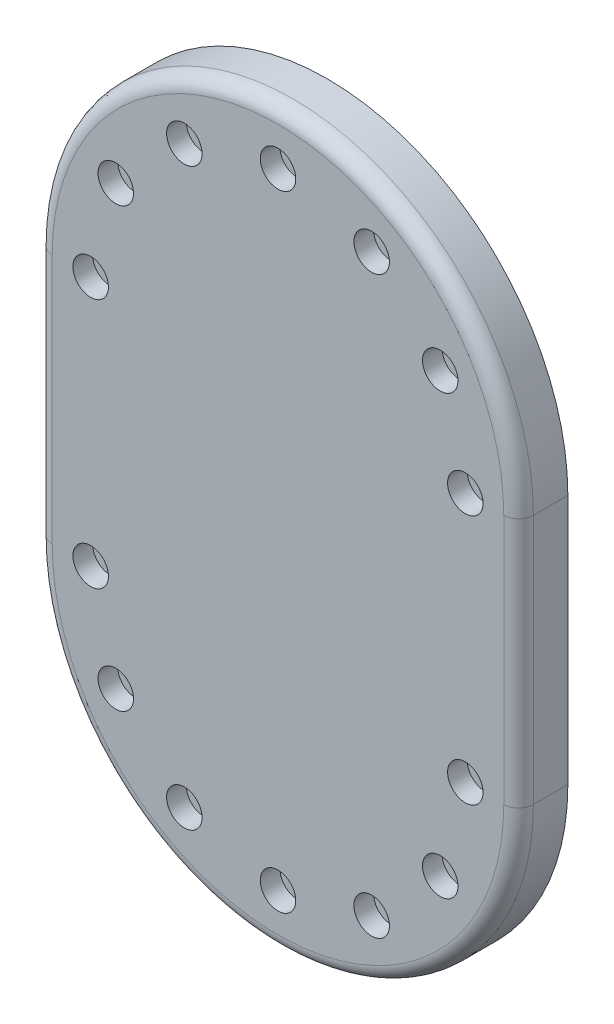
from build123d import *

# Parameters (mm, degrees)
BOSS_EXTRUDE1_DEPTH        = 12.5
CUT_EXTRUDE1_DEPTH         = 6.25
FILLET1_R                  = 1.75
FILLET2_R                  = 3.75
HOLE1_D                    = 5
HOLE1_DEPTH                = 30
HOLE1_CBORE_D              = 9
HOLE1_CBORE_DEPTH          = 5
CIRPATTERN1_COUNT          = 7
CIRPATTERN1_ANGLE          = 180
MIRROR1_COPY_1_D           = 5
MIRROR1_COPY_1_DEPTH       = 30
MIRROR1_COPY_1_CBORE_D     = 9
MIRROR1_COPY_1_CBORE_DEPTH = 5
MIRROR1_COPY_2_D           = 5
MIRROR1_COPY_2_DEPTH       = 30
MIRROR1_COPY_2_CBORE_D     = 9
MIRROR1_COPY_2_CBORE_DEPTH = 5
MIRROR1_COPY_3_D           = 5
MIRROR1_COPY_3_DEPTH       = 30
MIRROR1_COPY_3_CBORE_D     = 9
MIRROR1_COPY_3_CBORE_DEPTH = 5
MIRROR1_COPY_4_D           = 5
MIRROR1_COPY_4_DEPTH       = 30
MIRROR1_COPY_4_CBORE_D     = 9
MIRROR1_COPY_4_CBORE_DEPTH = 5
MIRROR1_COPY_5_D           = 5
MIRROR1_COPY_5_DEPTH       = 30
MIRROR1_COPY_5_CBORE_D     = 9
MIRROR1_COPY_5_CBORE_DEPTH = 5
MIRROR1_COPY_6_D           = 5
MIRROR1_COPY_6_DEPTH       = 30
MIRROR1_COPY_6_CBORE_D     = 9
MIRROR1_COPY_6_CBORE_DEPTH = 5


with BuildPart() as part:
    # Sketch1 → Boss-Extrude1 (new body)
    with BuildSketch(Plane.XY):
        with BuildLine():
            Line((61, 31.75), (61, -31.75))
            ThreePointArc((61, -31.75), (0, -92.75), (-61, -31.75))
            Line((-61, -31.75), (-61, 31.75))
            ThreePointArc((-61, 31.75), (0, 92.75), (61, 31.75))
        make_face()
    extrude(amount=BOSS_EXTRUDE1_DEPTH)

    # Sketch1_3 → Cut-Extrude1 (cut)
    with BuildSketch(Plane.XY):
        with BuildLine():
            Line((-11.5, 31.75), (-11.5, -31.75))
            ThreePointArc((-11.5, -31.75), (0, -43.25), (11.5, -31.75))
            Line((11.5, -31.75), (11.5, 31.75))
            ThreePointArc((11.5, 31.75), (0, 43.25), (-11.5, 31.75))
        make_face()
    extrude(amount=CUT_EXTRUDE1_DEPTH, mode=Mode.SUBTRACT)

    # Fillet1
    fillet1_edges = [part.edges().sort_by_distance(p)[0] for p in [
        (-11.5, 0, 0),
        (0, -43.25, 0),
        (0, 43.25, 0),
        (11.5, 0, 0),
    ]]
    fillet(fillet1_edges, radius=FILLET1_R)

    # Fillet2
    fillet2_edges = [part.edges().sort_by_distance(p)[0] for p in [
        (0, -92.75, 12.5),
        (61, 0, 12.5),
        (0, 92.75, 12.5),
        (-61, 0, 12.5),
    ]]
    fillet(fillet2_edges, radius=FILLET2_R)

    # Hole1
    with Locations(Plane.XY.offset(12.5)):
        with Locations((-47.5, 31.75)):
            hole1 = CounterBoreHole(HOLE1_D / 2, HOLE1_CBORE_D / 2, HOLE1_CBORE_DEPTH, depth=HOLE1_DEPTH)

    # CirPattern1: Hole1 ×7 about axis
    cirpattern1_axis = Axis((0, 31.75, 0), (0, 0, -1))
    for i in range(1, CIRPATTERN1_COUNT):
        add(hole1.rotate(cirpattern1_axis, i * CIRPATTERN1_ANGLE / (CIRPATTERN1_COUNT - 1)), mode=Mode.SUBTRACT)

    # Mirror1: Hole1 across plane
    add(hole1.mirror(Plane.ZX), mode=Mode.SUBTRACT)

    # Mirror1 copy 1
    with Locations(Plane(origin=(-15.875, -4.25369343, 12.5), x_dir=(0.866025404, 0.5, 0), z_dir=(0, 0, 1))):
        with Locations((-47.5, -31.75)):
            CounterBoreHole(MIRROR1_COPY_1_D / 2, MIRROR1_COPY_1_CBORE_D / 2, MIRROR1_COPY_1_CBORE_DEPTH, depth=MIRROR1_COPY_1_DEPTH)

    # Mirror1 copy 2
    with Locations(Plane(origin=(-27.49630657, -15.875, 12.5), x_dir=(0.5, 0.866025404, 0), z_dir=(0, 0, 1))):
        with Locations((-47.5, -31.75)):
            CounterBoreHole(MIRROR1_COPY_2_D / 2, MIRROR1_COPY_2_CBORE_D / 2, MIRROR1_COPY_2_CBORE_DEPTH, depth=MIRROR1_COPY_2_DEPTH)

    # Mirror1 copy 3
    with Locations(Plane(origin=(-31.75, -31.75, 12.5), x_dir=(0, 1, 0), z_dir=(0, 0, 1))):
        with Locations((-47.5, -31.75)):
            CounterBoreHole(MIRROR1_COPY_3_D / 2, MIRROR1_COPY_3_CBORE_D / 2, MIRROR1_COPY_3_CBORE_DEPTH, depth=MIRROR1_COPY_3_DEPTH)

    # Mirror1 copy 4
    with Locations(Plane(origin=(-27.49630657, -47.625, 12.5), x_dir=(-0.5, 0.866025404, 0), z_dir=(0, 0, 1))):
        with Locations((-47.5, -31.75)):
            CounterBoreHole(MIRROR1_COPY_4_D / 2, MIRROR1_COPY_4_CBORE_D / 2, MIRROR1_COPY_4_CBORE_DEPTH, depth=MIRROR1_COPY_4_DEPTH)

    # Mirror1 copy 5
    with Locations(Plane(origin=(-15.875, -59.24630657, 12.5), x_dir=(-0.866025404, 0.5, 0), z_dir=(0, 0, 1))):
        with Locations((-47.5, -31.75)):
            CounterBoreHole(MIRROR1_COPY_5_D / 2, MIRROR1_COPY_5_CBORE_D / 2, MIRROR1_COPY_5_CBORE_DEPTH, depth=MIRROR1_COPY_5_DEPTH)

    # Mirror1 copy 6
    with Locations(Plane(origin=(0, -63.5, 12.5), x_dir=(-1, 0, 0), z_dir=(0, 0, 1))):
        with Locations((-47.5, -31.75)):
            CounterBoreHole(MIRROR1_COPY_6_D / 2, MIRROR1_COPY_6_CBORE_D / 2, MIRROR1_COPY_6_CBORE_DEPTH, depth=MIRROR1_COPY_6_DEPTH)


solid = part.part
